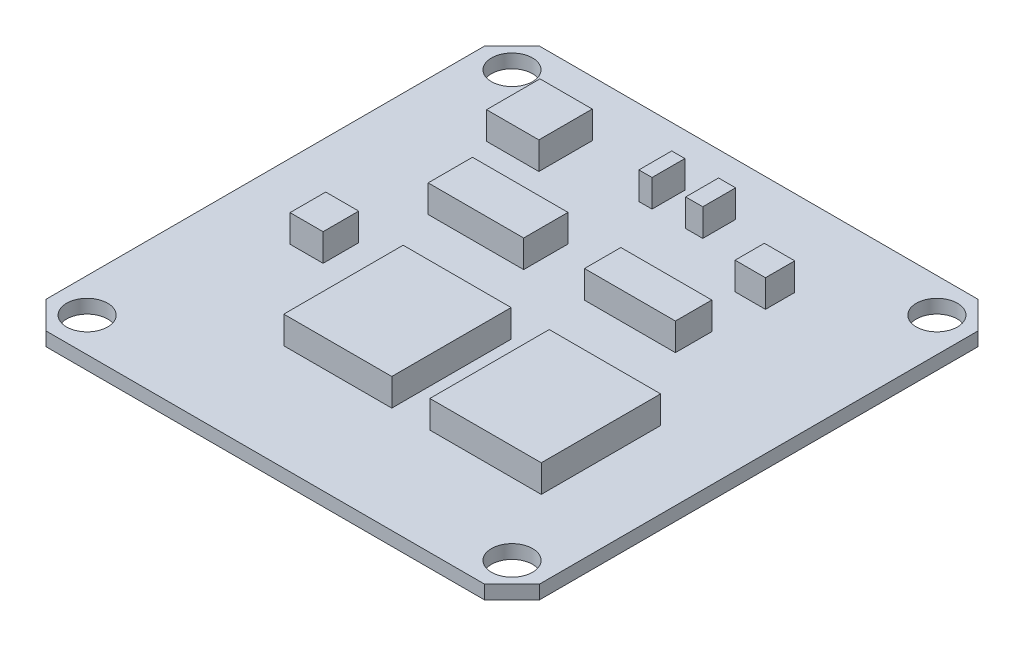
from build123d import *

# Parameters (mm, degrees)
SKETCH1_W            = 36
SKETCH1_H            = 36
BOSS_EXTRUDE1_DEPTH  = 1
SKETCH2_W            = 3.81533948
SKETCH2_H            = 3.898281644
SKETCH2_W_2          = 7.879505449
SKETCH2_H_2          = 8.708927076
SKETCH2_W_3          = 8.128331937
SKETCH2_W_4          = 6.63537301
SKETCH2_H_3          = 2.654149204
SKETCH2_W_5          = 6.967141661
SKETCH2_H_4          = 3.234744343
SKETCH2_W_6          = 0.958696997
SKETCH2_H_5          = 2.396742492
SKETCH2_W_7          = 1.244132439
BOSS_EXTRUDE2_DEPTH  = 2
CHAMFER1_SIZE        = 2
SKETCH3_W            = 2.408590064
SKETCH3_H            = 2.601230853
SKETCH3_W_2          = 2.217469356
SKETCH3_H_2          = 2.137281434
BOSS_EXTRUDE3_DEPTH  = 2
SKETCH4_R            = 1.5
CUT_EXTRUDE1_DEPTH   = 2
LPATTERN1_COUNT      = 2
LPATTERN1_PITCH      = 31
LPATTERN1_COUNT_DIR2 = 2
LPATTERN1_PITCH_DIR2 = 31


with BuildPart() as part:
    # Sketch1 → Boss-Extrude1 (new body)
    with BuildSketch(Plane(origin=(0, 0, 0), x_dir=(1, 0, 0), z_dir=(0, 1, 0))):
        Rectangle(SKETCH1_W, SKETCH1_H)
    extrude(amount=BOSS_EXTRUDE1_DEPTH)

    # Sketch2 → Boss-Extrude2 (add)
    with BuildSketch(Plane(origin=(0, 1, 0), x_dir=(1, 0, 0), z_dir=(0, 1, 0))):
        with Locations((-10, 12)):
            Rectangle(SKETCH2_W, SKETCH2_H)
        with Locations((-2.446793798, -5.909629087)):
            Rectangle(SKETCH2_W_2, SKETCH2_H_2)
        with Locations((8.335687344, -5.909629087)):
            Rectangle(SKETCH2_W_3, SKETCH2_H_2)
        with Locations((5.018000839, 4.914323135)):
            Rectangle(SKETCH2_W_4, SKETCH2_H_3)
        with Locations((-5.930364628, 4.914323136)):
            Rectangle(SKETCH2_W_5, SKETCH2_H_4)
        with Locations((-2.06525985, 13.001183991)):
            Rectangle(SKETCH2_W_6, SKETCH2_H_5)
        with Locations((1.492958928, 13.001183991)):
            Rectangle(SKETCH2_W_7, SKETCH2_H_5)
    extrude(amount=BOSS_EXTRUDE2_DEPTH)

    # Chamfer1
    chamfer1_edges = [part.edges().sort_by_distance(p)[0] for p in [
        (18, 0.5, 18),
        (-18, 0.5, 18),
        (-18, 0.5, -18),
        (18, 0.5, -18),
    ]]
    chamfer(chamfer1_edges, length=CHAMFER1_SIZE)

    # Sketch3 → Boss-Extrude3 (add)
    with BuildSketch(Plane(origin=(0, 1, 0), x_dir=(1, 0, 0), z_dir=(0, 1, 0))):
        with Locations((-11.367372892, -2.320698042)):
            Rectangle(SKETCH3_W, SKETCH3_H)
        with Locations((7.776721419, 10.675684916)):
            Rectangle(SKETCH3_W_2, SKETCH3_H_2)
    extrude(amount=BOSS_EXTRUDE3_DEPTH)

    # Sketch4 → Cut-Extrude1 (cut, through all)
    with BuildSketch(Plane(origin=(0, 1, 0), x_dir=(1, 0, 0), z_dir=(0, 1, 0))):
        with Locations((-15.5, 15.5)):
            Circle(SKETCH4_R)
    cut_extrude1 = extrude(amount=-CUT_EXTRUDE1_DEPTH, mode=Mode.SUBTRACT)

    # LPattern1: Cut-Extrude1 2 × 2
    with Locations(*[(i * LPATTERN1_PITCH, 0, j * LPATTERN1_PITCH_DIR2) for i in range(LPATTERN1_COUNT) for j in range(LPATTERN1_COUNT_DIR2) if (i, j) != (0, 0)]):
        add(cut_extrude1, mode=Mode.SUBTRACT)


solid = part.part
